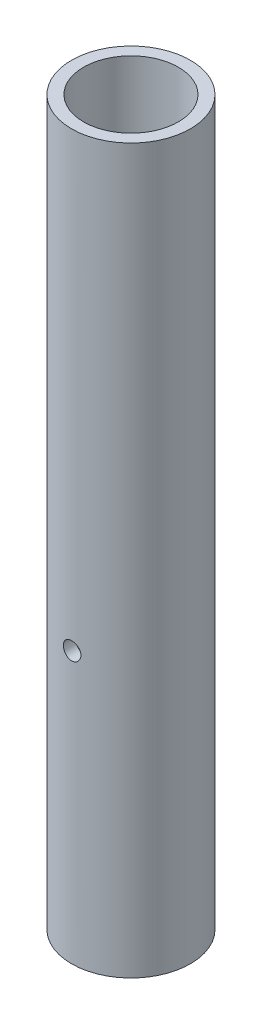
from build123d import *

# Parameters (mm, degrees)
SKETCH1_R                    = 16.7005
SKETCH1_R_2                  = 13.3223
BOSS_EXTRUDE1_DEPTH          = 203.2
F_10_0_1935_DIAMETER_HOLE1_D = 4.9149


with BuildPart() as part:
    # Sketch1 → Boss-Extrude1 (new body)
    with BuildSketch(Plane(origin=(0, 0, 0), x_dir=(1, 0, 0), z_dir=(0, 1, 0))):
        Circle(SKETCH1_R)
        Circle(SKETCH1_R_2, mode=Mode.SUBTRACT)
    extrude(amount=BOSS_EXTRUDE1_DEPTH)

    # #10 (0.1935) Diameter Hole1 (through all)
    with Locations(Plane.XY.offset(16.7005)):
        with Locations((0, 76.2)):
            Hole(F_10_0_1935_DIAMETER_HOLE1_D / 2)


solid = part.part
